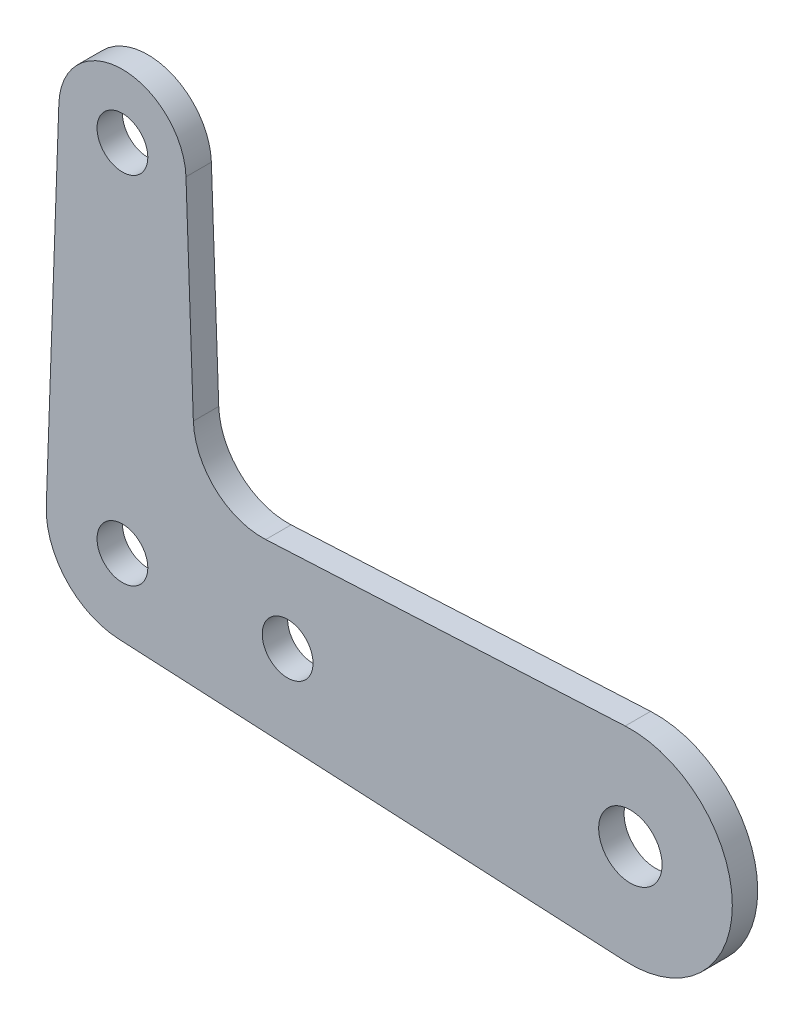
from build123d import *

# Parameters (mm, degrees)
SKETCH2_R           = 1.25
SKETCH2_R_2         = 1.56
BOSS_EXTRUDE1_DEPTH = 1.25


with BuildPart() as part:
    # Sketch2 → Boss-Extrude1 (new body)
    with BuildSketch(Plane.XY):
        with BuildLine():
            Line((-3.747645792, 0.132857143), (-3.128035021, 17.610891429))
            ThreePointArc((-3.128035021, 17.610891429), (0, 20.63), (3.128035021, 17.610891429))
            Line((3.128035021, 17.610891429), (3.490733982, 7.379847717))
            ThreePointArc((3.490733982, 7.379847717), (4.587445605, 5.000849133), (7.052010693, 4.11296988))
            Line((7.052010693, 4.11296988), (24.745488645, 5.011535084))
            ThreePointArc((24.745488645, 5.011535084), (30.017993615, 0), (24.745488645, -5.011535084))
            Line((24.745488645, -5.011535084), (-0.190199042, -3.745173471))
            ThreePointArc((-0.190199042, -3.745173471), (-2.763410184, -2.534968275), (-3.747645792, 0.132857143))
        make_face()
        with Locations((0, 17.5)):
            Circle(SKETCH2_R, mode=Mode.SUBTRACT)
        Circle(SKETCH2_R, mode=Mode.SUBTRACT)
        with Locations((8.13, 0)):
            Circle(SKETCH2_R, mode=Mode.SUBTRACT)
        with Locations((25, 0)):
            Circle(SKETCH2_R_2, mode=Mode.SUBTRACT)
    extrude(amount=BOSS_EXTRUDE1_DEPTH)


solid = part.part
